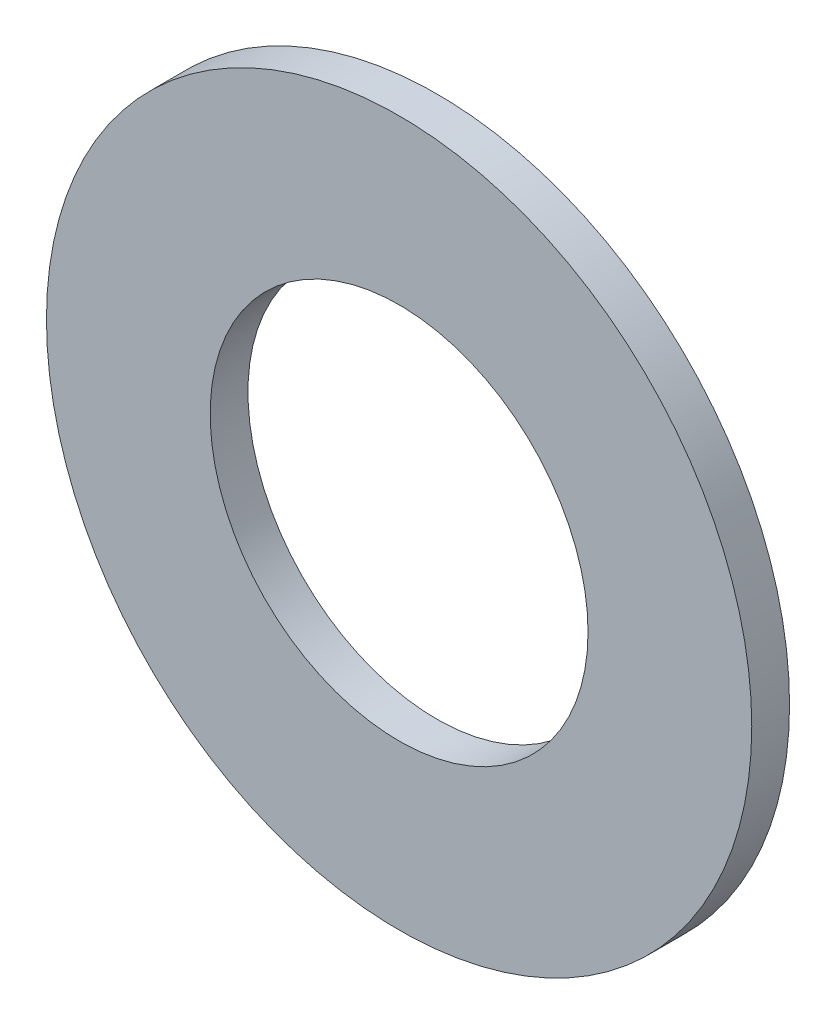
from build123d import *

# Parameters (mm, degrees)
SKETCH1_R           = 14
SKETCH1_R_2         = 7.5
BOSS_EXTRUDE1_DEPTH = 1.5


with BuildPart() as part:
    # Sketch1 → Boss-Extrude1 (new body)
    with BuildSketch(Plane.XY):
        Circle(SKETCH1_R)
        Circle(SKETCH1_R_2, mode=Mode.SUBTRACT)
    extrude(amount=BOSS_EXTRUDE1_DEPTH)


solid = part.part
